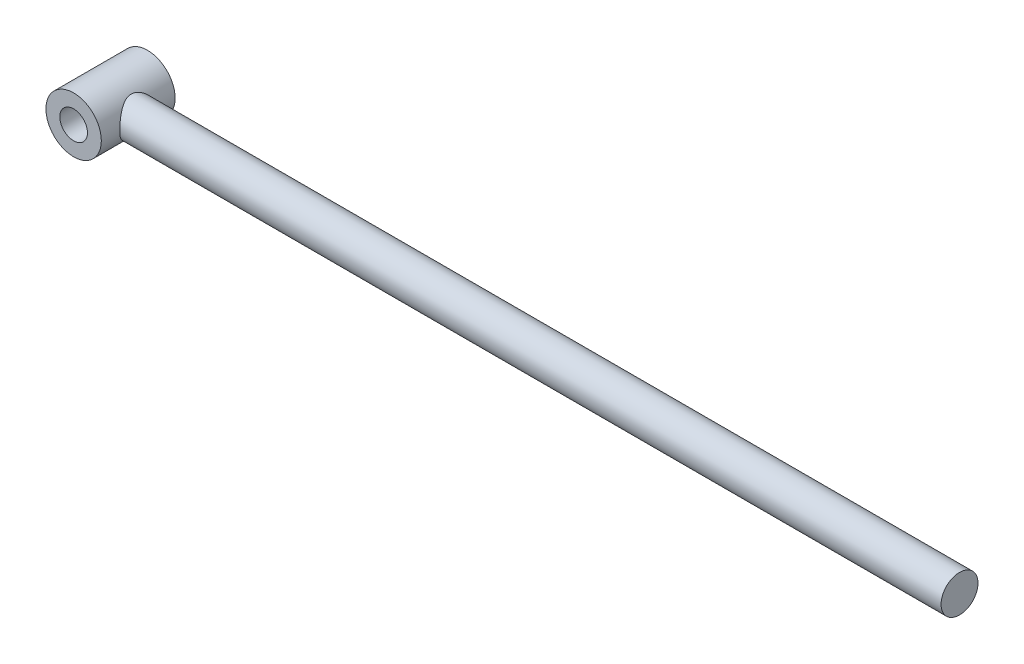
from build123d import *

# Parameters (mm, degrees)
SKETCH1_R           = 30
SKETCH1_R_2         = 15
BOSS_EXTRUDE1_DEPTH = 40
SKETCH2_R           = 20
BOSS_EXTRUDE2_DEPTH = 900


with BuildPart() as part:
    # Sketch1 → Boss-Extrude1 (new body, symmetric)
    with BuildSketch(Plane.XY):
        Circle(SKETCH1_R)
        Circle(SKETCH1_R_2, mode=Mode.SUBTRACT)
    extrude(amount=BOSS_EXTRUDE1_DEPTH, both=True)

    # Sketch2 → Boss-Extrude2 (add)
    with BuildSketch(Plane(origin=(20, 0, 0), x_dir=(0, 0, -1), z_dir=(1, 0, 0))):
        Circle(SKETCH2_R)
    extrude(amount=BOSS_EXTRUDE2_DEPTH)


solid = part.part
